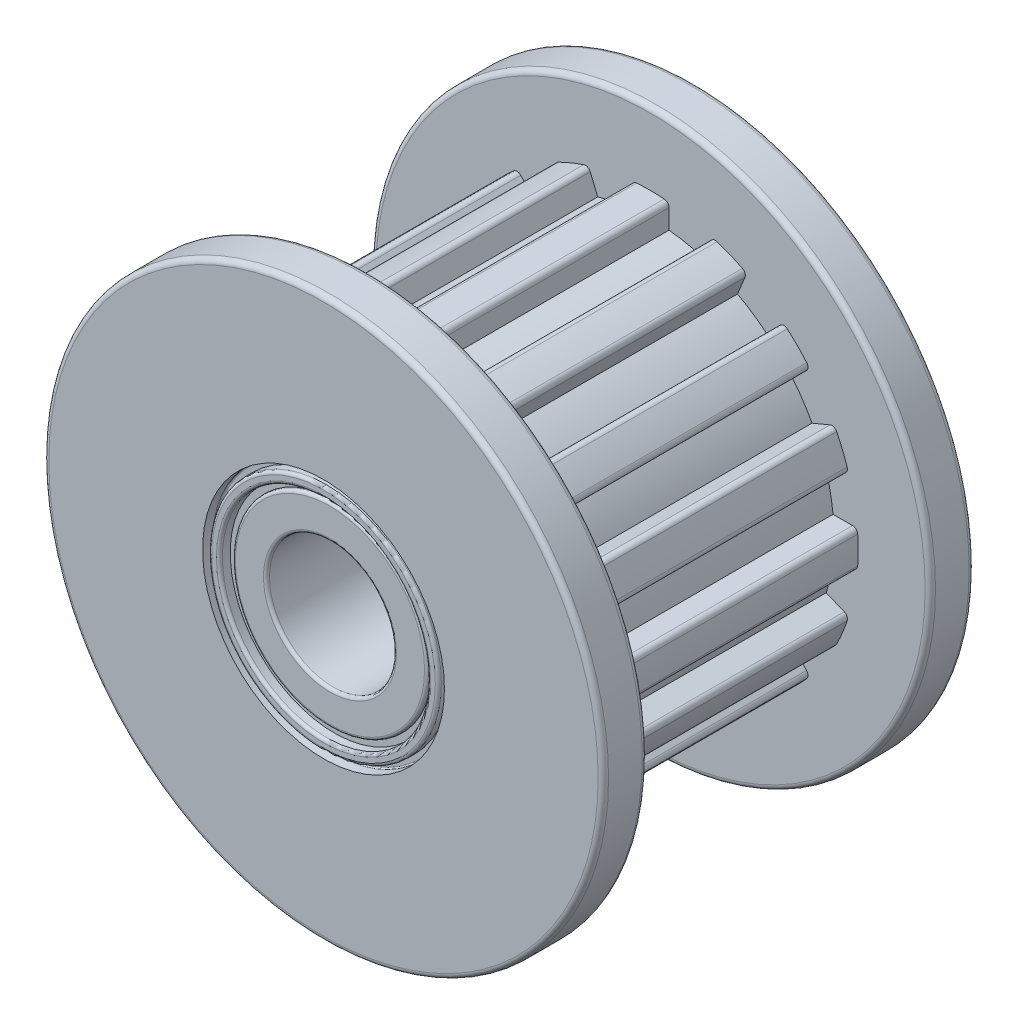
from build123d import *

# Parameters (mm, degrees)
RESSALTO_EXTRUS_O3_DEPTH   = 6.55
ESBO_O3_R                  = 6.48
RESSALTO_EXTRUS_O4_DEPTH   = 1.02
ESBO_O4_R                  = 6.48
RESSALTO_EXTRUS_O5_DEPTH   = 1.02
FILETE2_R                  = 0.12
ESBO_O5_R                  = 1.47
CORTE_EXTRUS_O1_DEPTH      = 10
CORTE_EXTRUS_O1_DEPTH_BACK = 10.02
ESBO_O6_R                  = 2.26
CORTE_EXTRUS_O3_DEPTH      = 0.15
ESBO_O8_R                  = 2.26
CORTE_EXTRUS_O4_DEPTH      = 0.15
ESBO_O9_R                  = 2.41
ESBO_O9_R_2                = 2.26
CORTE_EXTRUS_O7_DEPTH      = 0.25
ESBO_O11_R                 = 2.46
ESBO_O11_R_2               = 2.26
CORTE_EXTRUS_O8_DEPTH      = 0.25
FILETE4_R                  = 0.07
FILETE5_R                  = 0.07
ESBO_O12_R                 = 2.8
ESBO_O12_R_2               = 2.66
CORTE_EXTRUS_O10_DEPTH     = 0.25
FILETE6_R                  = 0.07
FILETE7_R                  = 0.03
ESBO_O13_R                 = 2.8
ESBO_O13_R_2               = 2.65
CORTE_EXTRUS_O11_DEPTH     = 0.25
FILETE8_R                  = 0.03
FILETE9_R                  = 0.07


with BuildPart() as part:
    # Esboço2 → Ressalto-extrusão3 (new body)
    with BuildSketch(Plane.XY):
        with BuildLine():
            Line((-0.43, 4.679743583), (-0.43, 4.228191103))
            ThreePointArc((-0.43, 4.228191103), (-0.829133869, 4.168337442), (-1.220790485, 4.070893095))
            Line((-1.220790485, 4.070893095), (-1.393592138, 4.488073189))
            ThreePointArc((-1.393592138, 4.488073189), (-1.454894778, 4.551437584), (-1.542951268, 4.55580963))
            ThreePointArc((-1.542951268, 4.55580963), (-1.84070731, 4.443860551), (-2.130412578, 4.312475188))
            ThreePointArc((-2.130412578, 4.312475188), (-2.189586416, 4.247118343), (-2.188128536, 4.158965438))
            Line((-2.188128536, 4.158965438), (-2.015326883, 3.741785343))
            ThreePointArc((-2.015326883, 3.741785343), (-2.36117349, 3.533745852), (-2.685726685, 3.293838517))
            Line((-2.685726685, 3.293838517), (-3.005022506, 3.613134337))
            ThreePointArc((-3.005022506, 3.613134337), (-3.085907265, 3.6482159), (-3.168933963, 3.618557384))
            ThreePointArc((-3.168933963, 3.618557384), (-3.401183618, 3.401183618), (-3.618557384, 3.168933963))
            ThreePointArc((-3.618557384, 3.168933963), (-3.6482159, 3.085907265), (-3.613134337, 3.005022506))
            Line((-3.613134337, 3.005022506), (-3.293838517, 2.685726685))
            ThreePointArc((-3.293838517, 2.685726685), (-3.533745852, 2.36117349), (-3.741785343, 2.015326883))
            Line((-3.741785343, 2.015326883), (-4.158965438, 2.188128536))
            ThreePointArc((-4.158965438, 2.188128536), (-4.247118343, 2.189586416), (-4.312475188, 2.130412578))
            ThreePointArc((-4.312475188, 2.130412578), (-4.443860551, 1.84070731), (-4.55580963, 1.542951268))
            ThreePointArc((-4.55580963, 1.542951268), (-4.551437584, 1.454894778), (-4.488073189, 1.393592138))
            Line((-4.488073189, 1.393592138), (-4.070893095, 1.220790485))
            ThreePointArc((-4.070893095, 1.220790485), (-4.168337442, 0.829133869), (-4.228191103, 0.43))
            Line((-4.228191103, 0.43), (-4.679743583, 0.43))
            ThreePointArc((-4.679743583, 0.43), (-4.761744155, 0.397612249), (-4.799481158, 0.31793177))
            ThreePointArc((-4.799481158, 0.31793177), (-4.81, 0), (-4.799481158, -0.31793177))
            ThreePointArc((-4.799481158, -0.31793177), (-4.761744155, -0.397612249), (-4.679743583, -0.43))
            Line((-4.679743583, -0.43), (-4.228191103, -0.43))
            ThreePointArc((-4.228191103, -0.43), (-4.168337442, -0.829133869), (-4.070893095, -1.220790485))
            Line((-4.070893095, -1.220790485), (-4.488073189, -1.393592138))
            ThreePointArc((-4.488073189, -1.393592138), (-4.551437584, -1.454894778), (-4.55580963, -1.542951268))
            ThreePointArc((-4.55580963, -1.542951268), (-4.443860551, -1.84070731), (-4.312475188, -2.130412578))
            ThreePointArc((-4.312475188, -2.130412578), (-4.247118343, -2.189586416), (-4.158965438, -2.188128536))
            Line((-4.158965438, -2.188128536), (-3.741785343, -2.015326883))
            ThreePointArc((-3.741785343, -2.015326883), (-3.533745852, -2.36117349), (-3.293838517, -2.685726685))
            Line((-3.293838517, -2.685726685), (-3.613134337, -3.005022506))
            ThreePointArc((-3.613134337, -3.005022506), (-3.6482159, -3.085907265), (-3.618557384, -3.168933963))
            ThreePointArc((-3.618557384, -3.168933963), (-3.401183618, -3.401183618), (-3.168933963, -3.618557384))
            ThreePointArc((-3.168933963, -3.618557384), (-3.085907265, -3.6482159), (-3.005022506, -3.613134337))
            Line((-3.005022506, -3.613134337), (-2.685726685, -3.293838517))
            ThreePointArc((-2.685726685, -3.293838517), (-2.400184002, -3.507366071), (-2.097748191, -3.696207858))
            Line((-2.097748191, -3.696207858), (-2.015326883, -3.741785343))
            Line((-2.015326883, -3.741785343), (-2.188128536, -4.158965438))
            ThreePointArc((-2.188128536, -4.158965438), (-2.189586416, -4.247118343), (-2.130412578, -4.312475188))
            ThreePointArc((-2.130412578, -4.312475188), (-1.84070731, -4.443860551), (-1.542951268, -4.55580963))
            ThreePointArc((-1.542951268, -4.55580963), (-1.454894778, -4.551437584), (-1.393592138, -4.488073189))
            Line((-1.393592138, -4.488073189), (-1.220790485, -4.070893095))
            ThreePointArc((-1.220790485, -4.070893095), (-0.829133869, -4.168337442), (-0.43, -4.228191103))
            Line((-0.43, -4.228191103), (-0.43, -4.679743583))
            ThreePointArc((-0.43, -4.679743583), (-0.397612249, -4.761744155), (-0.31793177, -4.799481158))
            ThreePointArc((-0.31793177, -4.799481158), (0, -4.81), (0.31793177, -4.799481158))
            ThreePointArc((0.31793177, -4.799481158), (0.397612249, -4.761744155), (0.43, -4.679743583))
            Line((0.43, -4.679743583), (0.43, -4.228191103))
            ThreePointArc((0.43, -4.228191103), (0.829133869, -4.168337442), (1.220790485, -4.070893095))
            Line((1.220790485, -4.070893095), (1.393592138, -4.488073189))
            ThreePointArc((1.393592138, -4.488073189), (1.454894778, -4.551437584), (1.542951268, -4.55580963))
            ThreePointArc((1.542951268, -4.55580963), (1.84070731, -4.443860551), (2.130412578, -4.312475188))
            ThreePointArc((2.130412578, -4.312475188), (2.189586416, -4.247118343), (2.188128536, -4.158965438))
            Line((2.188128536, -4.158965438), (2.015326883, -3.741785343))
            ThreePointArc((2.015326883, -3.741785343), (2.36117349, -3.533745852), (2.685726685, -3.293838517))
            Line((2.685726685, -3.293838517), (3.005022506, -3.613134337))
            ThreePointArc((3.005022506, -3.613134337), (3.085907265, -3.6482159), (3.168933963, -3.618557384))
            ThreePointArc((3.168933963, -3.618557384), (3.401183618, -3.401183618), (3.618557384, -3.168933963))
            ThreePointArc((3.618557384, -3.168933963), (3.6482159, -3.085907265), (3.613134337, -3.005022506))
            Line((3.613134337, -3.005022506), (3.293838517, -2.685726685))
            ThreePointArc((3.293838517, -2.685726685), (3.533745852, -2.36117349), (3.741785343, -2.015326883))
            Line((3.741785343, -2.015326883), (4.158965438, -2.188128536))
            ThreePointArc((4.158965438, -2.188128536), (4.247118343, -2.189586416), (4.312475188, -2.130412578))
            ThreePointArc((4.312475188, -2.130412578), (4.443860551, -1.84070731), (4.55580963, -1.542951268))
            ThreePointArc((4.55580963, -1.542951268), (4.551437584, -1.454894778), (4.488073189, -1.393592138))
            Line((4.488073189, -1.393592138), (4.070893095, -1.220790485))
            ThreePointArc((4.070893095, -1.220790485), (4.168337442, -0.829133869), (4.228191103, -0.43))
            Line((4.228191103, -0.43), (4.679743583, -0.43))
            ThreePointArc((4.679743583, -0.43), (4.761744155, -0.397612249), (4.799481158, -0.31793177))
            ThreePointArc((4.799481158, -0.31793177), (4.81, 0), (4.799481158, 0.31793177))
            ThreePointArc((4.799481158, 0.31793177), (4.761744155, 0.397612249), (4.679743583, 0.43))
            Line((4.679743583, 0.43), (4.228191103, 0.43))
            ThreePointArc((4.228191103, 0.43), (4.168337442, 0.829133869), (4.070893095, 1.220790485))
            Line((4.070893095, 1.220790485), (4.488073189, 1.393592138))
            ThreePointArc((4.488073189, 1.393592138), (4.551437584, 1.454894778), (4.55580963, 1.542951268))
            ThreePointArc((4.55580963, 1.542951268), (4.443860551, 1.84070731), (4.312475188, 2.130412578))
            ThreePointArc((4.312475188, 2.130412578), (4.247118343, 2.189586416), (4.158965438, 2.188128536))
            Line((4.158965438, 2.188128536), (3.741785343, 2.015326883))
            ThreePointArc((3.741785343, 2.015326883), (3.533745852, 2.36117349), (3.293838517, 2.685726685))
            Line((3.293838517, 2.685726685), (3.613134337, 3.005022506))
            ThreePointArc((3.613134337, 3.005022506), (3.6482159, 3.085907265), (3.618557384, 3.168933963))
            ThreePointArc((3.618557384, 3.168933963), (3.401183618, 3.401183618), (3.168933963, 3.618557384))
            ThreePointArc((3.168933963, 3.618557384), (3.085907265, 3.6482159), (3.005022506, 3.613134337))
            Line((3.005022506, 3.613134337), (2.685726685, 3.293838517))
            ThreePointArc((2.685726685, 3.293838517), (2.36117349, 3.533745852), (2.015326883, 3.741785343))
            Line((2.015326883, 3.741785343), (2.188128536, 4.158965438))
            ThreePointArc((2.188128536, 4.158965438), (2.189586416, 4.247118343), (2.130412578, 4.312475188))
            ThreePointArc((2.130412578, 4.312475188), (1.84070731, 4.443860551), (1.542951268, 4.55580963))
            ThreePointArc((1.542951268, 4.55580963), (1.454894778, 4.551437584), (1.393592138, 4.488073189))
            Line((1.393592138, 4.488073189), (1.220790485, 4.070893095))
            ThreePointArc((1.220790485, 4.070893095), (0.829133869, 4.168337442), (0.43, 4.228191103))
            Line((0.43, 4.228191103), (0.43, 4.679743583))
            ThreePointArc((0.43, 4.679743583), (0.397612249, 4.761744155), (0.31793177, 4.799481158))
            ThreePointArc((0.31793177, 4.799481158), (0, 4.81), (-0.31793177, 4.799481158))
            ThreePointArc((-0.31793177, 4.799481158), (-0.397612249, 4.761744155), (-0.43, 4.679743583))
        make_face()
    extrude(amount=RESSALTO_EXTRUS_O3_DEPTH)

    # Esboço3 → Ressalto-extrusão4 (add)
    with BuildSketch(Plane.XY.offset(6.55)):
        Circle(ESBO_O3_R)
    extrude(amount=RESSALTO_EXTRUS_O4_DEPTH)

    # Esboço4 → Ressalto-extrusão5 (add)
    with BuildSketch(Plane(origin=(0, 0, 0), x_dir=(-1, 0, 0), z_dir=(0, 0, -1))):
        Circle(ESBO_O4_R)
    extrude(amount=RESSALTO_EXTRUS_O5_DEPTH)

    # Filete2
    filete2_edges = [part.edges().sort_by_distance(p)[0] for p in [
        (-6.48, 0, 6.55),
        (-6.48, 0, 7.57),
        (6.48, 0, 0),
        (6.48, 0, -1.02),
    ]]
    fillet(filete2_edges, radius=FILETE2_R)

    # Esboço5 → Corte-extrusão1 (cut, two sides)
    with BuildSketch(Plane.XY.offset(7.57)) as corte_extrus_o1_sk:
        Circle(ESBO_O5_R)
    extrude(amount=CORTE_EXTRUS_O1_DEPTH, mode=Mode.SUBTRACT)
    extrude(corte_extrus_o1_sk.sketch, amount=-CORTE_EXTRUS_O1_DEPTH_BACK, mode=Mode.SUBTRACT)

    # Esboço6 → Corte-extrusão3 (cut)
    with BuildSketch(Plane.XY.offset(7.57)):
        Circle(ESBO_O6_R)
    extrude(amount=-CORTE_EXTRUS_O3_DEPTH, mode=Mode.SUBTRACT)

    # Esboço8 → Corte-extrusão4 (cut)
    with BuildSketch(Plane(origin=(0, 0, -1.02), x_dir=(-1, 0, 0), z_dir=(0, 0, -1))):
        Circle(ESBO_O8_R)
    extrude(amount=-CORTE_EXTRUS_O4_DEPTH, mode=Mode.SUBTRACT)

    # Esboço9 → Corte-extrusão7 (cut)
    with BuildSketch(Plane.XY.offset(7.57)):
        Circle(ESBO_O9_R)
        Circle(ESBO_O9_R_2, mode=Mode.SUBTRACT)
    extrude(amount=-CORTE_EXTRUS_O7_DEPTH, mode=Mode.SUBTRACT)

    # Esboço11 → Corte-extrusão8 (cut)
    with BuildSketch(Plane(origin=(0, 0, -1.02), x_dir=(-1, 0, 0), z_dir=(0, 0, -1))):
        Circle(ESBO_O11_R)
        Circle(ESBO_O11_R_2, mode=Mode.SUBTRACT)
    extrude(amount=-CORTE_EXTRUS_O8_DEPTH, mode=Mode.SUBTRACT)

    # Filete4
    filete4_edges = [part.edges().sort_by_distance(p)[0] for p in [
        (-1.47, 0, -0.87),
        (2.26, 0, -0.87),
    ]]
    fillet(filete4_edges, radius=FILETE4_R)

    # Filete5
    filete5_edges = [part.edges().sort_by_distance(p)[0] for p in [
        (-1.47, 0, 7.42),
        (-2.26, 0, 7.42),
    ]]
    fillet(filete5_edges, radius=FILETE5_R)

    # Esboço12 → Corte-extrusão10 (cut)
    with BuildSketch(Plane.XY.offset(7.57)):
        Circle(ESBO_O12_R)
        Circle(ESBO_O12_R_2, mode=Mode.SUBTRACT)
    extrude(amount=-CORTE_EXTRUS_O10_DEPTH, mode=Mode.SUBTRACT)

    # Filete6
    filete6_edges = [part.edges().sort_by_distance(p)[0] for p in [
        (-2.41, 0, 7.57),
        (-2.66, 0, 7.57),
    ]]
    fillet(filete6_edges, radius=FILETE6_R)

    # Filete7
    filete7_edges = [part.edges().sort_by_distance(p)[0] for p in [
        (-2.8, 0, 7.32),
    ]]
    fillet(filete7_edges, radius=FILETE7_R)

    # Esboço13 → Corte-extrusão11 (cut)
    with BuildSketch(Plane(origin=(0, 0, -1.02), x_dir=(-1, 0, 0), z_dir=(0, 0, -1))):
        Circle(ESBO_O13_R)
        Circle(ESBO_O13_R_2, mode=Mode.SUBTRACT)
    extrude(amount=-CORTE_EXTRUS_O11_DEPTH, mode=Mode.SUBTRACT)

    # Filete8
    filete8_edges = [part.edges().sort_by_distance(p)[0] for p in [
        (2.46, 0, -1.02),
        (2.65, 0, -1.02),
    ]]
    fillet(filete8_edges, radius=FILETE8_R)

    # Filete9
    filete9_edges = [part.edges().sort_by_distance(p)[0] for p in [
        (2.8, 0, -1.02),
    ]]
    fillet(filete9_edges, radius=FILETE9_R)


solid = part.part
